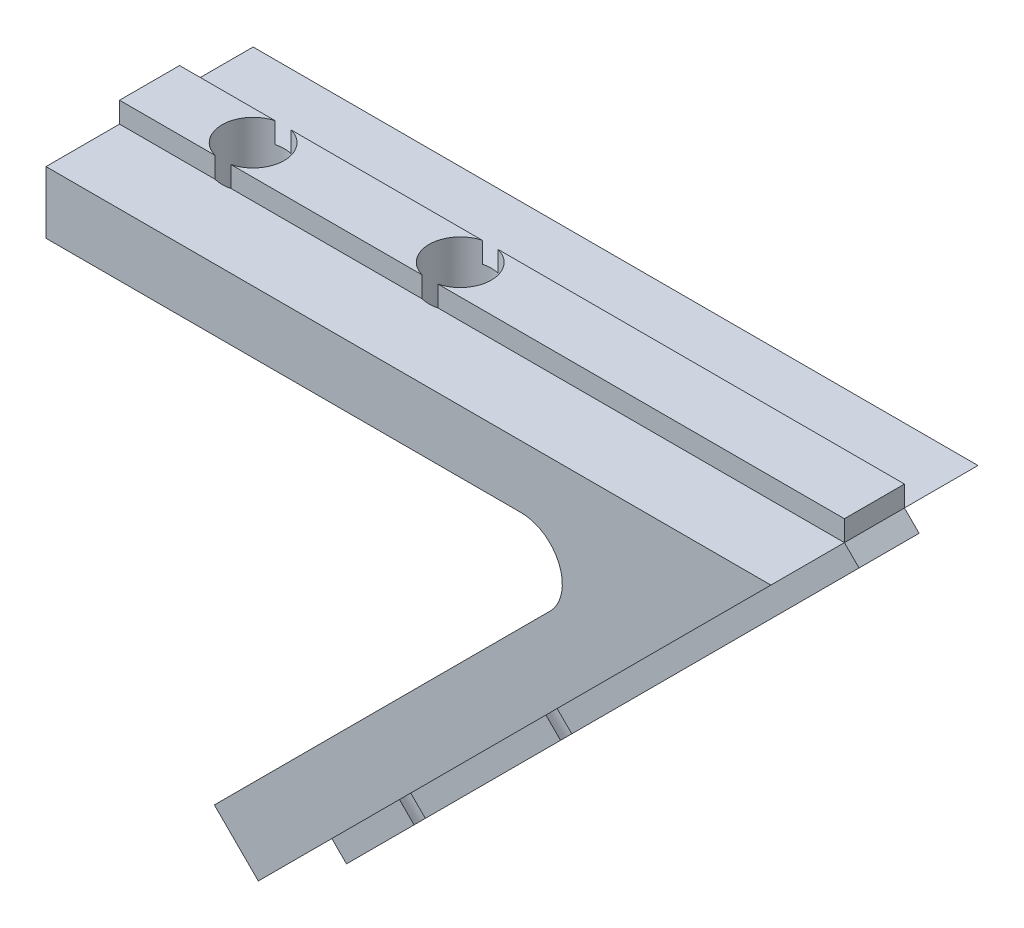
from build123d import *

# Parameters (mm, degrees)
BOSS_EXTRU_1_DEPTH      = 10
ESQUISSE2_W             = 35
ESQUISSE2_H             = 2.9
BOSS_EXTRU_2_DEPTH      = 1
ESQUISSE3_W             = 35
ESQUISSE3_H             = 2.9
BOSS_EXTRU_3_DEPTH      = 1
ESQUISSE4_R             = 1.5
ENL_V_MAT_EXTRU_1_DEPTH = 5
ESQUISSE5_R             = 1.5
ENL_V_MAT_EXTRU_2_DEPTH = 22.5


with BuildPart() as part:
    # Esquisse1 → Boss.-Extru.1 (new body)
    with BuildSketch(Plane.XY):
        with BuildLine():
            Line((0, 0), (35, 0))
            Line((35, 0), (10.251262658, -24.748737342))
            Line((10.251262658, -24.748737342), (8.129942315, -22.627416998))
            Line((8.129942315, -22.627416998), (24.343145751, -6.414213562))
            ThreePointArc((24.343145751, -6.414213562), (24.776691253, -4.234633135), (22.928932188, -3))
            Line((22.928932188, -3), (0, -3))
            Line((0, -3), (0, 0))
        make_face()
    extrude(amount=BOSS_EXTRU_1_DEPTH)

    # Esquisse2 → Boss.-Extru.2 (add)
    with BuildSketch(Plane(origin=(0, 0, 0), x_dir=(1, 0, 0), z_dir=(0, 1, 0))):
        with Locations((17.5, -5)):
            Rectangle(ESQUISSE2_W, ESQUISSE2_H)
    extrude(amount=BOSS_EXTRU_2_DEPTH)

    # Esquisse3 → Boss.-Extru.3 (add)
    with BuildSketch(Plane(origin=(17.5, -17.5, 0), x_dir=(0.707106781, 0.707106781, 0), z_dir=(0.707106781, -0.707106781, 0))):
        with Locations((7.248737342, 5)):
            Rectangle(ESQUISSE3_W, ESQUISSE3_H)
    extrude(amount=BOSS_EXTRU_3_DEPTH)

    # Esquisse4 → Enlèv. mat.-Extru.1 (cut, through all)
    with BuildSketch(Plane.XZ.offset(3)):
        with Locations((5, 5)):
            Circle(ESQUISSE4_R)
        with Locations((15, 5)):
            Circle(ESQUISSE4_R)
    extrude(amount=-ENL_V_MAT_EXTRU_1_DEPTH, mode=Mode.SUBTRACT)

    # Esquisse5 → Enlèv. mat.-Extru.2 (cut, through all)
    with BuildSketch(Plane(origin=(15.378679656, -15.378679656, 0), x_dir=(0.707106781, 0.707106781, 0), z_dir=(-0.707106781, 0.707106781, 0))):
        with Locations((-5.251262658, -5)):
            Circle(ESQUISSE5_R)
        with Locations((4.748737342, -5)):
            Circle(ESQUISSE5_R)
    extrude(amount=-ENL_V_MAT_EXTRU_2_DEPTH, mode=Mode.SUBTRACT)


solid = part.part
